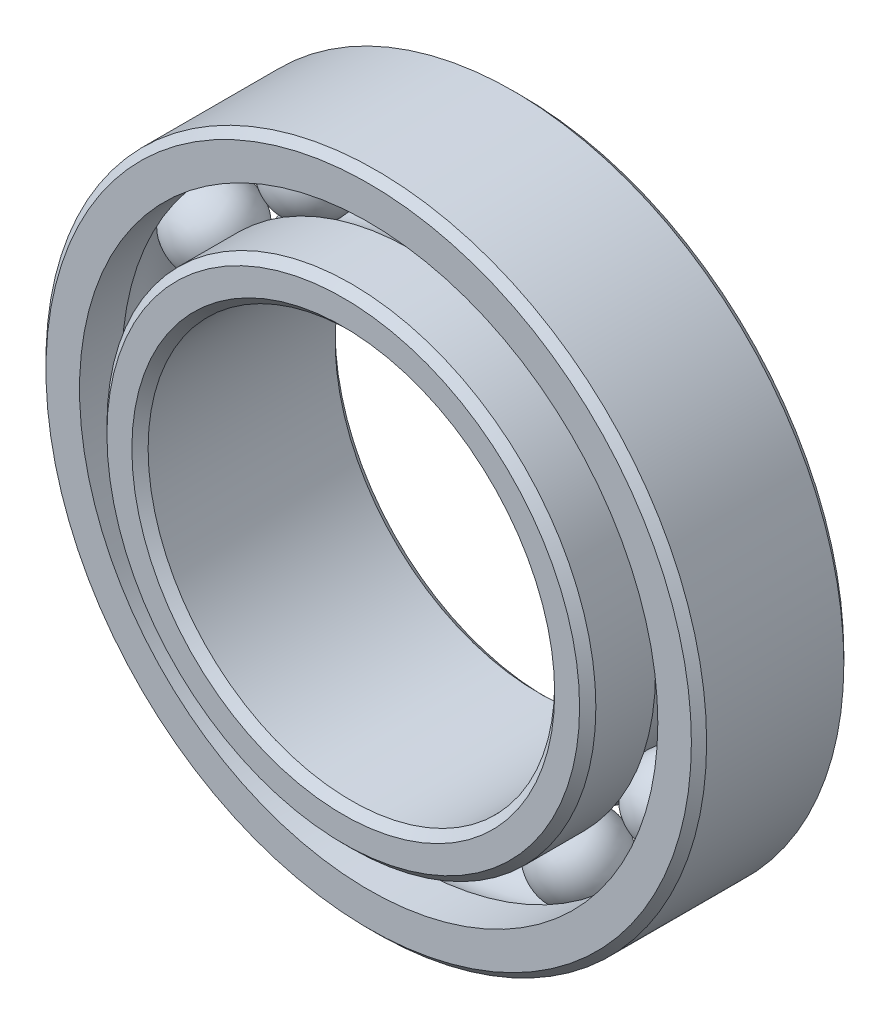
from build123d import *

# Parameters (mm, degrees)
CIRPATTERN1_COUNT = 12
CHAMFER1_SIZE     = 0.508


with BuildPart() as part:
    # Sketch1 → Revolve1 (revolve)
    with BuildSketch(Plane(origin=(0, 0, 0), x_dir=(0, 0, -1), z_dir=(1, 0, 0))):
        with BuildLine():
            Line((4.28625, 20.6375), (-4.28625, 20.6375))
            Line((-4.28625, 20.6375), (-4.7625, 20.16125))
            Line((-4.7625, 20.16125), (-4.7625, 18.064354396))
            Line((-4.7625, 18.064354396), (-2.116666667, 18.064354396))
            ThreePointArc((-2.116666667, 18.064354396), (0, 19.204097985), (2.116666667, 18.064354396))
            Line((2.116666667, 18.064354396), (4.7625, 18.064354396))
            Line((4.7625, 18.064354396), (4.7625, 20.16125))
            Line((4.7625, 20.16125), (4.28625, 20.6375))
        make_face()
    revolve(axis=Axis((0, 0, 4.7625), (0, 0, -1)))


with BuildPart() as body_2:
    # Sketch3 → Revolve3 (revolve)
    with BuildSketch(Plane(origin=(0, 0, 0), x_dir=(0, 0, -1), z_dir=(1, 0, 0))):
        with BuildLine():
            Line((-6.35, 15.273145604), (-2.116666667, 15.273145604))
            ThreePointArc((-2.116666667, 15.273145604), (0, 14.133402015), (2.116666667, 15.273145604))
            Line((2.116666667, 15.273145604), (6.35, 15.273145604))
            Line((6.35, 15.273145604), (6.35, 12.7))
            Line((6.35, 12.7), (-6.35, 12.7))
            Line((-6.35, 12.7), (-6.35, 15.273145604))
        make_face()
    revolve(axis=Axis((0, 0, 4.7625), (0, 0, -1)))

    # Chamfer1
    chamfer1_edges = [body_2.edges().sort_by_distance(p)[0] for p in [
        (0, -12.7, 6.35),
        (0, -15.273145604, 6.35),
        (0, -15.273145604, -6.35),
        (0, -12.7, -6.35),
    ]]
    chamfer(chamfer1_edges, length=CHAMFER1_SIZE)


with BuildPart() as body_3:
    # Sketch4 → Revolve4 (revolve)
    with BuildSketch(Plane(origin=(0, 0, 0), x_dir=(0, 0, -1), z_dir=(1, 0, 0))):
        with BuildLine():
            Line((-2.535347985, 16.66875), (2.535347985, 16.66875))
            ThreePointArc((2.535347985, 16.66875), (0, 19.204097985), (-2.535347985, 16.66875))
        make_face()
    revolve(axis=Axis((0, 16.66875, 2.535347985), (0, 0, -1)))


with BuildPart() as cirpattern1_1:
    # CirPattern1: pattern copy
    add(body_3.part.rotate(Axis((0, 0, -4.7625), (0, 0, 1)), 1 * 360 / CIRPATTERN1_COUNT))


with BuildPart() as cirpattern1_2:
    # CirPattern1: pattern copy
    add(body_3.part.rotate(Axis((0, 0, -4.7625), (0, 0, 1)), 2 * 360 / CIRPATTERN1_COUNT))


with BuildPart() as cirpattern1_3:
    # CirPattern1: pattern copy
    add(body_3.part.rotate(Axis((0, 0, -4.7625), (0, 0, 1)), 3 * 360 / CIRPATTERN1_COUNT))


with BuildPart() as cirpattern1_4:
    # CirPattern1: pattern copy
    add(body_3.part.rotate(Axis((0, 0, -4.7625), (0, 0, 1)), 4 * 360 / CIRPATTERN1_COUNT))


with BuildPart() as cirpattern1_5:
    # CirPattern1: pattern copy
    add(body_3.part.rotate(Axis((0, 0, -4.7625), (0, 0, 1)), 5 * 360 / CIRPATTERN1_COUNT))


with BuildPart() as cirpattern1_6:
    # CirPattern1: pattern copy
    add(body_3.part.rotate(Axis((0, 0, -4.7625), (0, 0, 1)), 6 * 360 / CIRPATTERN1_COUNT))


with BuildPart() as cirpattern1_7:
    # CirPattern1: pattern copy
    add(body_3.part.rotate(Axis((0, 0, -4.7625), (0, 0, 1)), 7 * 360 / CIRPATTERN1_COUNT))


with BuildPart() as cirpattern1_8:
    # CirPattern1: pattern copy
    add(body_3.part.rotate(Axis((0, 0, -4.7625), (0, 0, 1)), 8 * 360 / CIRPATTERN1_COUNT))


with BuildPart() as cirpattern1_9:
    # CirPattern1: pattern copy
    add(body_3.part.rotate(Axis((0, 0, -4.7625), (0, 0, 1)), 9 * 360 / CIRPATTERN1_COUNT))


with BuildPart() as cirpattern1_10:
    # CirPattern1: pattern copy
    add(body_3.part.rotate(Axis((0, 0, -4.7625), (0, 0, 1)), 10 * 360 / CIRPATTERN1_COUNT))


with BuildPart() as cirpattern1_11:
    # CirPattern1: pattern copy
    add(body_3.part.rotate(Axis((0, 0, -4.7625), (0, 0, 1)), 11 * 360 / CIRPATTERN1_COUNT))


solid = Compound([part.part, body_2.part, body_3.part, cirpattern1_1.part, cirpattern1_2.part, cirpattern1_3.part, cirpattern1_4.part, cirpattern1_5.part, cirpattern1_6.part, cirpattern1_7.part, cirpattern1_8.part, cirpattern1_9.part, cirpattern1_10.part, cirpattern1_11.part])
